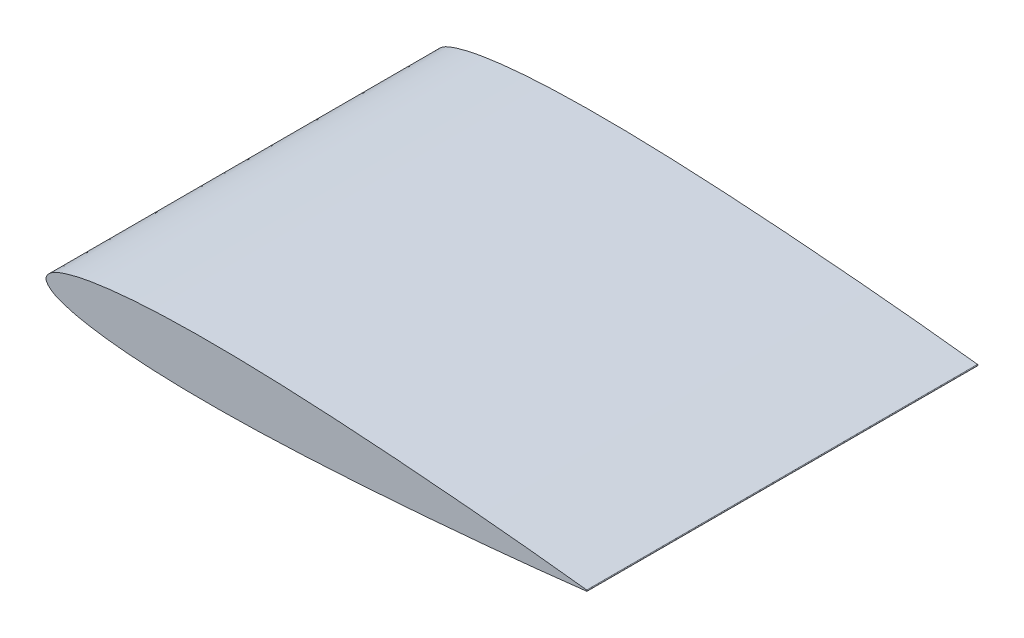
from build123d import *

# Parameters (mm, degrees)
BOSS_EXTRUDE1_DEPTH = 61


with BuildPart() as part:
    # Sketch1 → Boss-Extrude1 (new body)
    with BuildSketch(Plane.XY):
        with BuildLine():
            ThreePointArc((84.4, 0.08862), (84.479031413, 0), (84.4, -0.08862))
            add(Edge.make_bspline(
                [(84.4, 0.08862), (82.99354398, 0.250028543), (80.181611631, 0.572733197), (74.556242743, 1.172374926), (67.524408719, 1.861565682), (59.083875583, 2.591952538), (50.644045263, 3.229074083), (42.204012234, 3.748494441), (33.763427247, 4.118072827), (26.727032266, 4.2473469), (21.098926783, 4.196210749), (16.876895434, 4.057340988), (12.651857812, 3.789358064), (9.13369492, 3.416086631), (6.318312417, 2.968587515), (4.202282127, 2.531612376), (2.403159114, 1.976416661), (0.911077233, 1.348317949), (-0.53949518, 0), (0.911077233, -1.348317949), (2.403159114, -1.976416661), (4.202282127, -2.531612376), (6.318312417, -2.968587515), (9.13369492, -3.416086631), (12.651857812, -3.789358064), (16.876895434, -4.057340988), (21.098926783, -4.196210749), (26.727032266, -4.2473469), (33.763427247, -4.118072827), (42.204012234, -3.748494441), (50.644045263, -3.229074083), (59.083875583, -2.591952538), (67.524408719, -1.861565682), (74.556242743, -1.172374926), (80.181611631, -0.572733197), (82.99354398, -0.250028543), (84.4, -0.08862)],
                knots=[0, 0, 0, 0, 0.024823556, 0.049629821, 0.09919708, 0.148712653, 0.19818214, 0.247604473, 0.296979943, 0.346317596, 0.370984298, 0.39566402, 0.420382182, 0.445198051, 0.457689209, 0.470304283, 0.48322923, 0.490069174, 0.5, 0.509930826, 0.51677077, 0.529695717, 0.542310791, 0.554801949, 0.579617818, 0.60433598, 0.629015702, 0.653682404, 0.703020057, 0.752395527, 0.80181786, 0.851287347, 0.90080292, 0.950370179, 0.975176444, 1, 1, 1, 1], degree=3))
        make_face()
    extrude(amount=BOSS_EXTRUDE1_DEPTH)


solid = part.part
